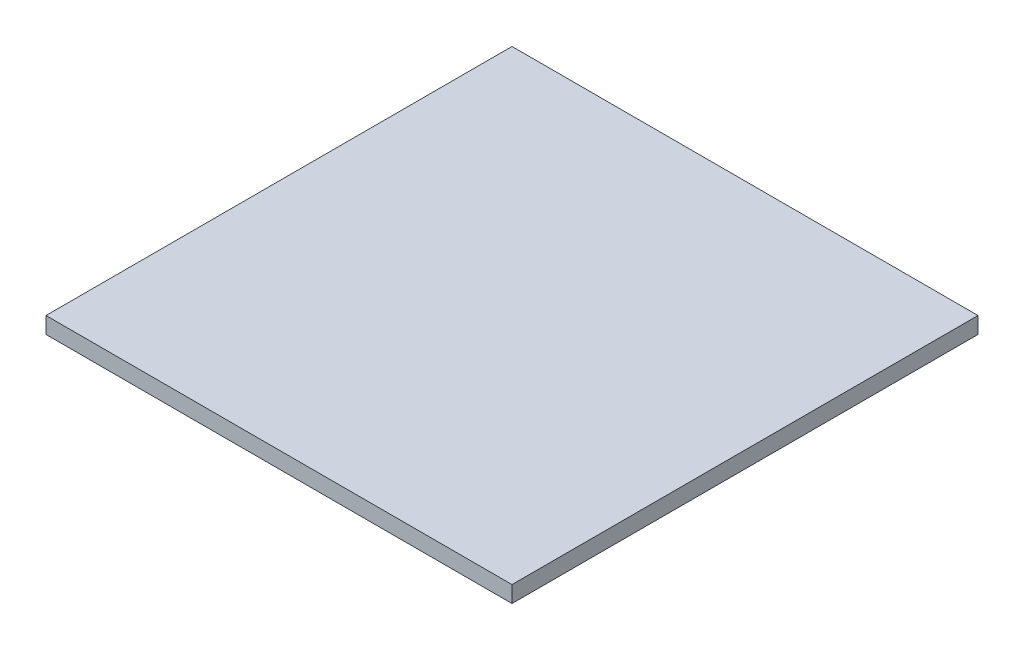
from build123d import *

# Parameters (mm, degrees)
SKETCH1_W           = 85
SKETCH1_H           = 85
BOSS_EXTRUDE1_DEPTH = 3


with BuildPart() as part:
    # Sketch1 → Boss-Extrude1 (new body)
    with BuildSketch(Plane(origin=(0, 0, 0), x_dir=(1, 0, 0), z_dir=(0, 1, 0))):
        Rectangle(SKETCH1_W, SKETCH1_H)
    extrude(amount=BOSS_EXTRUDE1_DEPTH)


solid = part.part
